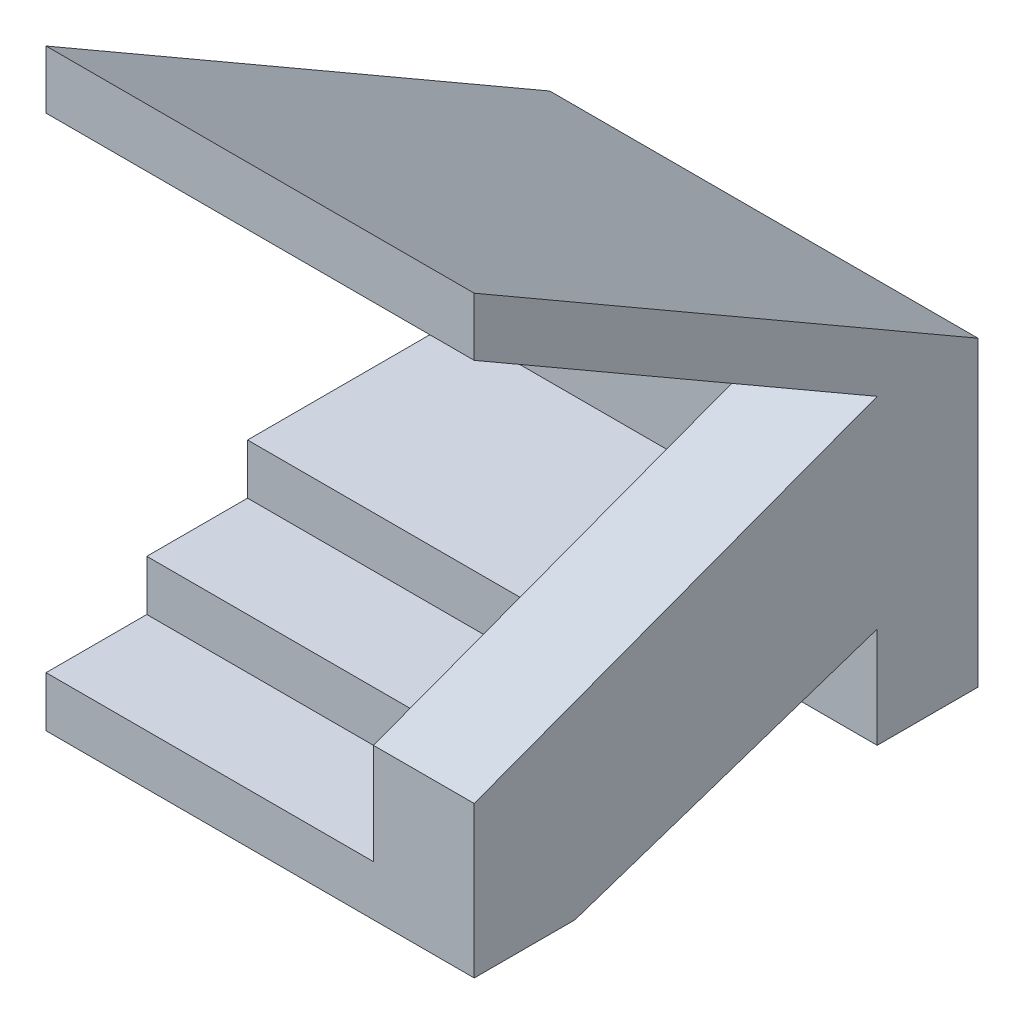
from build123d import *

# Parameters (mm, degrees)
STEPS_DEPTH     = 85
SIDE_WALL_DEPTH = 20


with BuildPart() as part:
    # Sketch1 → Steps (new body)
    with BuildSketch(Plane(origin=(0, 0, 0), x_dir=(0, 0, -1), z_dir=(1, 0, 0))):
        Polygon((0, 0), (0, 10), (20, 10), (20, 20), (40, 20), (40, 30), (80, 30), (80, 60), (0, 106.188021535), (0, 117.735026919), (100, 60), (100, 0), (80, 0), (80, 20), (20, 0), align=None)
    extrude(amount=STEPS_DEPTH)

    # Sketch2 → Side wall (add)
    with BuildSketch(Plane(origin=(85, 0, 0), x_dir=(0, 0, -1), z_dir=(1, 0, 0))):
        Polygon((0, 0), (0, 30), (80, 60), (100, 60), (100, 0), (80, 0), (80, 20), (20, 0), align=None)
    extrude(amount=-SIDE_WALL_DEPTH)


solid = part.part
